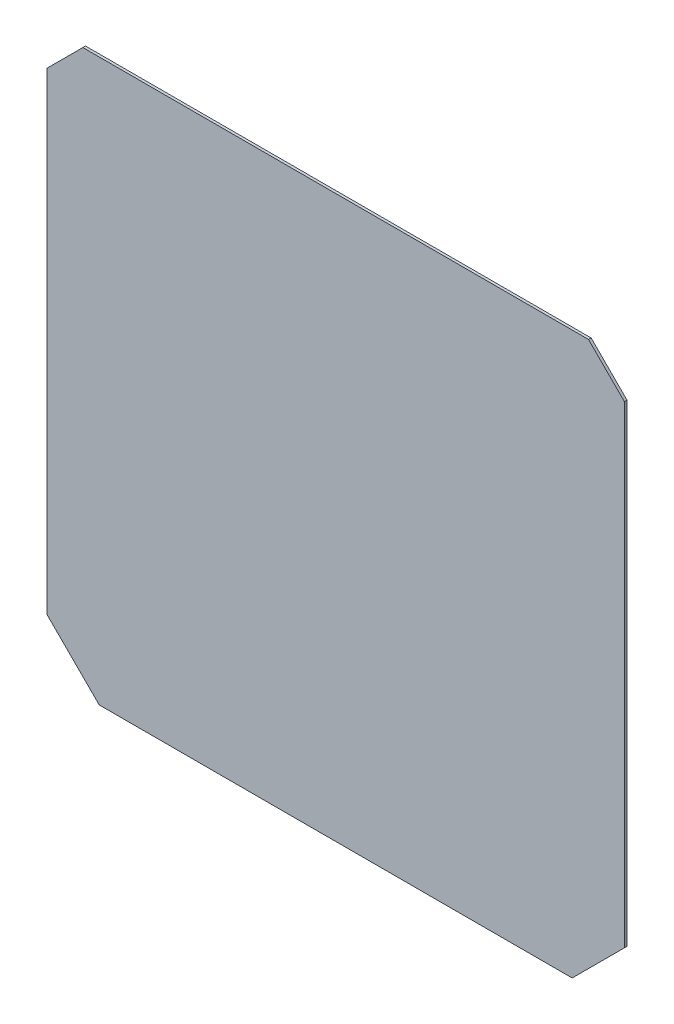
from build123d import *

# Parameters (mm, degrees)
EXTRUDE_1_DEPTH          = 2
SKETCH_3_W               = 440.695596705
SKETCH_3_H               = 44.042045092
CUT_EXTRUDE_1_DEPTH      = 10
CUT_EXTRUDE_1_DEPTH_BACK = 10


with BuildPart() as part:
    # 스케치1 → 보스-돌출1 (new body)
    with BuildSketch(Plane.XY):
        Polygon((-221, 181), (-181, 221), (181, 221), (221, 181), (221, -181), (181, -221), (-181, -221), (-221, -181), align=None)
    extrude(amount=EXTRUDE_1_DEPTH)

    # 스케치3 → 컷-돌출1 (cut, two sides)
    with BuildSketch(Plane.XY) as cut_extrude_1_sk:
        with Locations((5.347798353, 230.521022546)):
            Rectangle(SKETCH_3_W, SKETCH_3_H)
    extrude(amount=CUT_EXTRUDE_1_DEPTH, mode=Mode.SUBTRACT)
    extrude(cut_extrude_1_sk.sketch, amount=-CUT_EXTRUDE_1_DEPTH_BACK, mode=Mode.SUBTRACT)


solid = part.part
